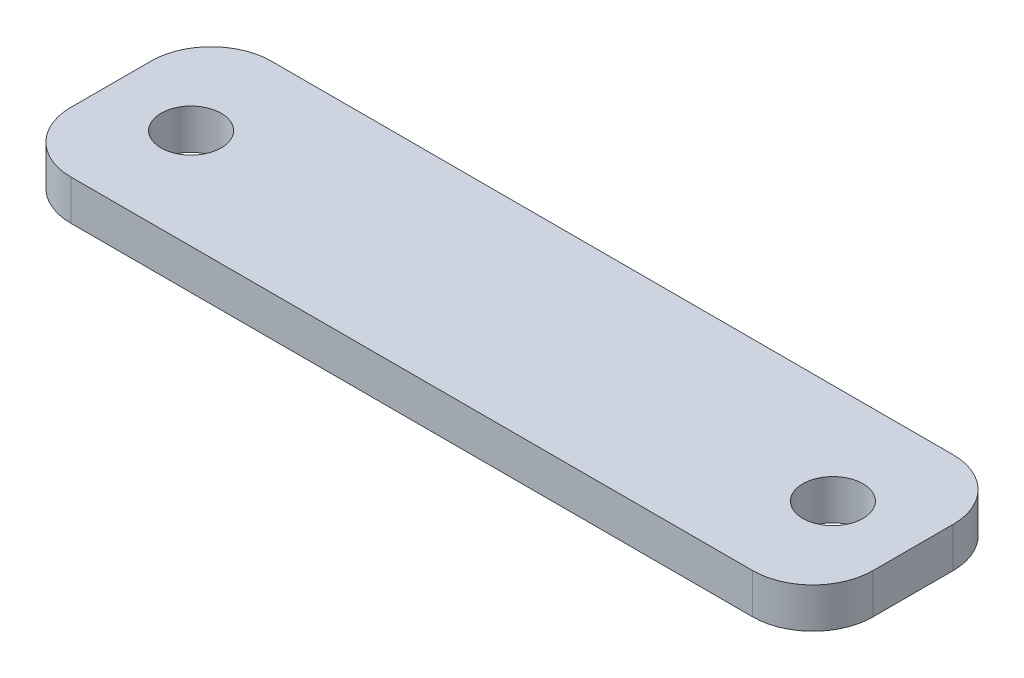
from build123d import *

# Parameters (mm, degrees)
SKETCH1_W             = 40
SKETCH1_H             = 10
BOSS_EXTRUDE1_DEPTH   = 2
FILLET1_R             = 3
F_3_0MM_DOWEL_HOLE1_D = 3


with BuildPart() as part:
    # Sketch1 → Boss-Extrude1 (new body)
    with BuildSketch(Plane(origin=(0, 0, 0), x_dir=(1, 0, 0), z_dir=(0, 1, 0))):
        Rectangle(SKETCH1_W, SKETCH1_H)
    extrude(amount=BOSS_EXTRUDE1_DEPTH)

    # Fillet1
    fillet1_edges = [part.edges().sort_by_distance(p)[0] for p in [
        (20, 1, 5),
        (-20, 1, 5),
        (-20, 1, -5),
        (20, 1, -5),
    ]]
    fillet(fillet1_edges, radius=FILLET1_R)

    # Ø3.0mm Dowel Hole1 (through all)
    with Locations(Plane(origin=(0, 2, 0), x_dir=(1, 0, 0), z_dir=(0, 1, 0))):
        with Locations((16, 0), (-16, 0)):
            Hole(F_3_0MM_DOWEL_HOLE1_D / 2)


solid = part.part
